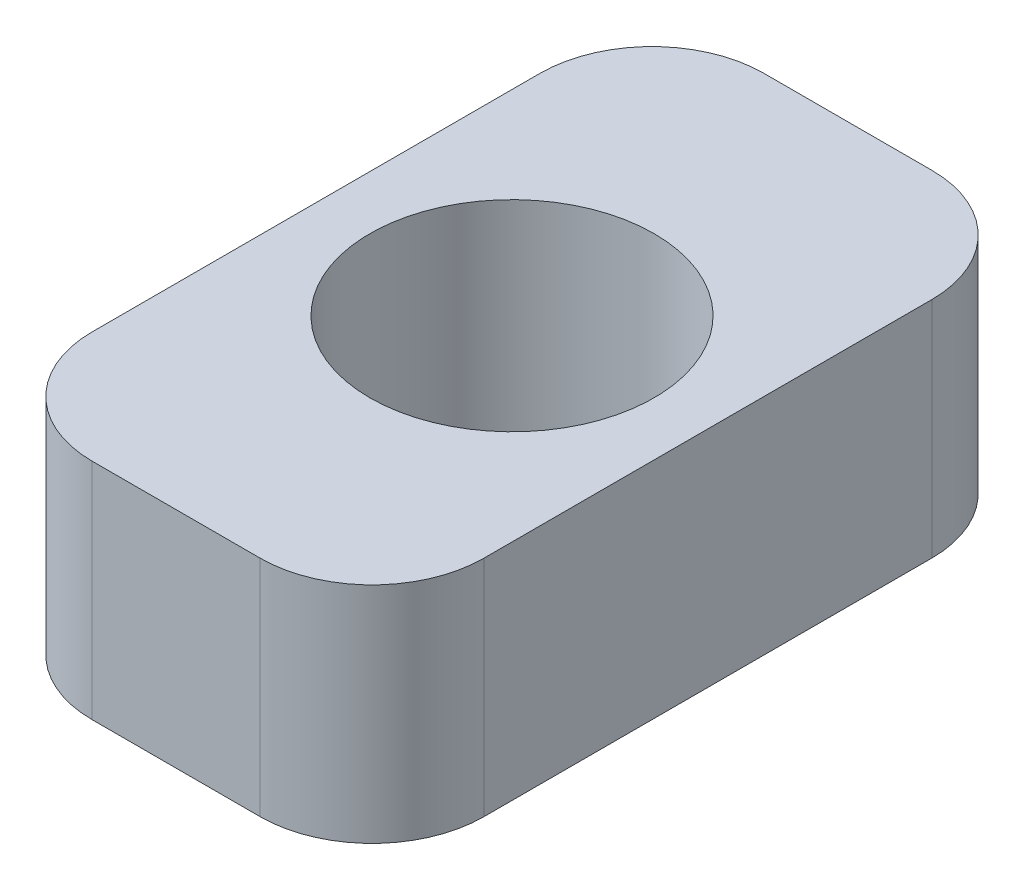
from build123d import *

# Parameters (mm, degrees)
SKETCH1_W           = 35
SKETCH1_H           = 60
SKETCH1_R           = 12.7
BOSS_EXTRUDE1_DEPTH = 20
FILLET1_R           = 10


with BuildPart() as part:
    # Sketch1 → Boss-Extrude1 (new body)
    with BuildSketch(Plane(origin=(0, 0, 0), x_dir=(1, 0, 0), z_dir=(0, 1, 0))):
        Rectangle(SKETCH1_W, SKETCH1_H)
        Circle(SKETCH1_R, mode=Mode.SUBTRACT)
    extrude(amount=BOSS_EXTRUDE1_DEPTH)

    # Fillet1
    fillet1_edges = [part.edges().sort_by_distance(p)[0] for p in [
        (17.5, 10, 30),
        (-17.5, 10, 30),
        (-17.5, 10, -30),
        (17.5, 10, -30),
    ]]
    fillet(fillet1_edges, radius=FILLET1_R)


solid = part.part
